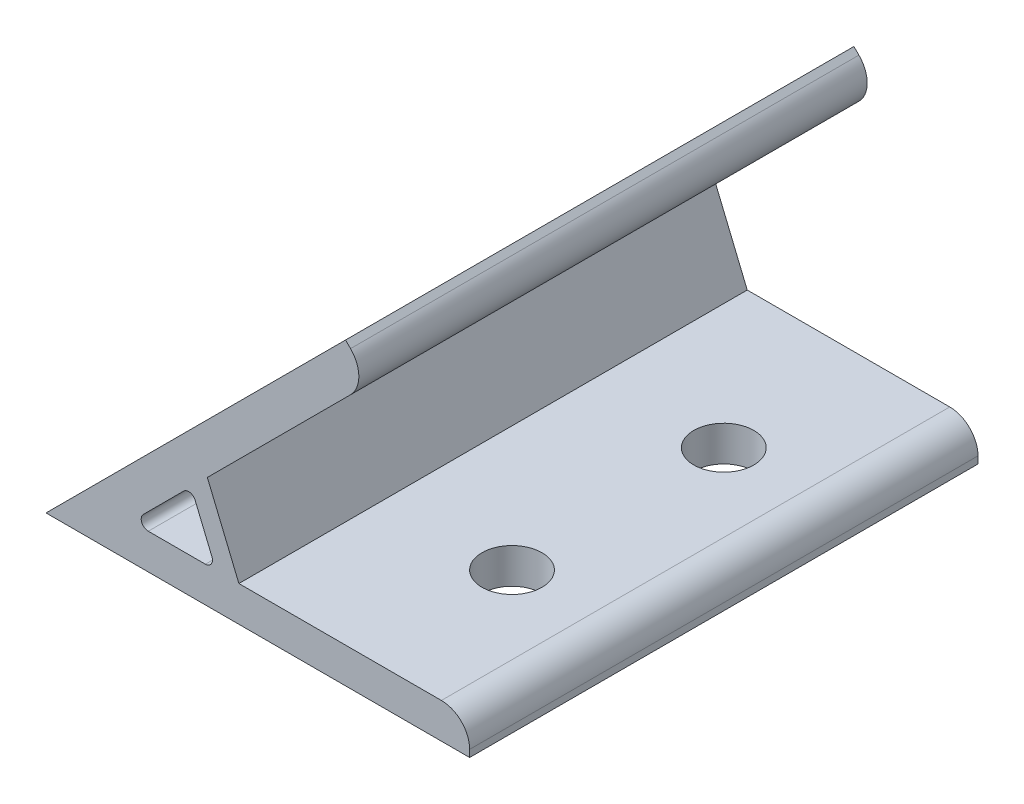
from build123d import *

# Parameters (mm, degrees)
EXTRUDE_1_DEPTH     = 36
SKETCH_2_R          = 4.25
CUT_EXTRUDE_1_DEPTH = 5
SKETCH_3_R          = 4.25
CUT_EXTRUDE_2_DEPTH = 5
FILLET_1_R          = 4
FILLET_2_R          = 1


with BuildPart() as part:
    # Эскиз1 → Бобышка-Вытянуть1 (new body, symmetric)
    with BuildSketch(Plane.XY):
        Polygon((0, 0), (42.426406871, 42.426406871), (45.961940777, 38.890872965), (22.85244978, 15.781381968), (27.318244413, 5), (60, 5), (60, 0), align=None)
        Polygon((20.556349186, 13.485281374), (24.071067812, 5), (12.071067812, 5), align=None, mode=Mode.SUBTRACT)
    extrude(amount=EXTRUDE_1_DEPTH, both=True)

    # Эскиз2 → Вырез-Вытянуть1 (cut)
    with BuildSketch(Plane(origin=(0, 0, 0), x_dir=(0, 0, 1), z_dir=(-0.707106781, 0.707106781, 0))):
        with Locations(Location((-20, 45, 0), (0, 0, 270))):  # turned: the seam where the file's is
            Circle(SKETCH_2_R)
        with Locations(Location((20, 45, 0), (0, 0, 270))):  # turned: the seam where the file's is
            Circle(SKETCH_2_R)
    extrude(amount=-CUT_EXTRUDE_1_DEPTH, mode=Mode.SUBTRACT)

    # Эскиз3 → Вырез-Вытянуть2 (cut)
    with BuildSketch(Plane.XZ):
        with Locations(Location((45, 15, 0), (0, 0, 270))):  # turned: the seam where the file's is
            Circle(SKETCH_3_R)
        with Locations(Location((45, -15, 0), (0, 0, 270))):  # turned: the seam where the file's is
            Circle(SKETCH_3_R)
    extrude(amount=-CUT_EXTRUDE_2_DEPTH, mode=Mode.SUBTRACT)

    # Скругление1
    fillet_1_edges = [part.edges().sort_by_distance(p)[0] for p in [
        (45.961940777, 38.890872965, 0),
        (60, 5, 0),
    ]]
    fillet(fillet_1_edges, radius=FILLET_1_R)

    # Скругление2
    fillet_2_edges = [part.edges().sort_by_distance(p)[0] for p in [
        (20.556349186, 13.485281374, 0),
        (12.071067812, 5, 0),
        (24.071067812, 5, 0),
    ]]
    fillet(fillet_2_edges, radius=FILLET_2_R)


solid = part.part
